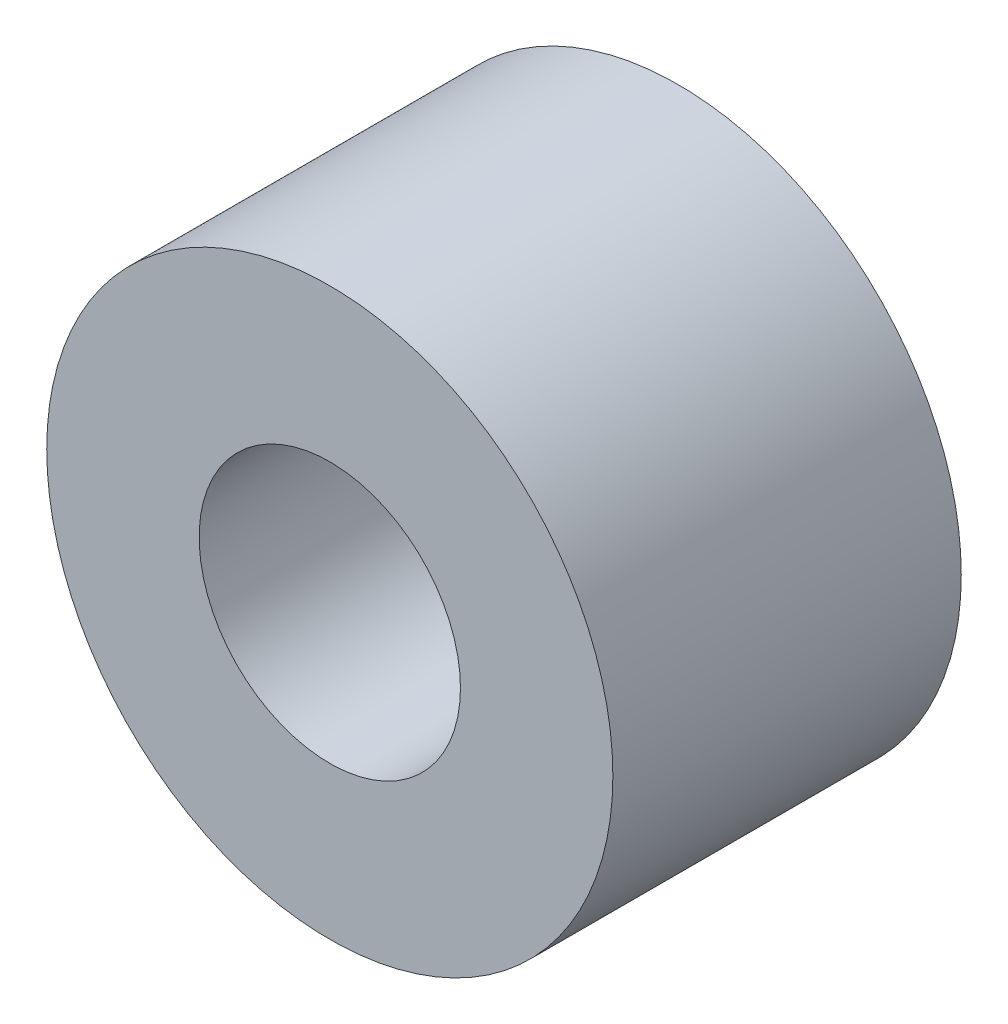
from build123d import *

# Parameters (mm, degrees)
SKETCH1_R           = 3.25
SKETCH1_R_2         = 1.5
BOSS_EXTRUDE1_DEPTH = 4


with BuildPart() as part:
    # Sketch1 → Boss-Extrude1 (new body)
    with BuildSketch(Plane.XY):
        Circle(SKETCH1_R)
        Circle(SKETCH1_R_2, mode=Mode.SUBTRACT)
    extrude(amount=BOSS_EXTRUDE1_DEPTH)


solid = part.part
